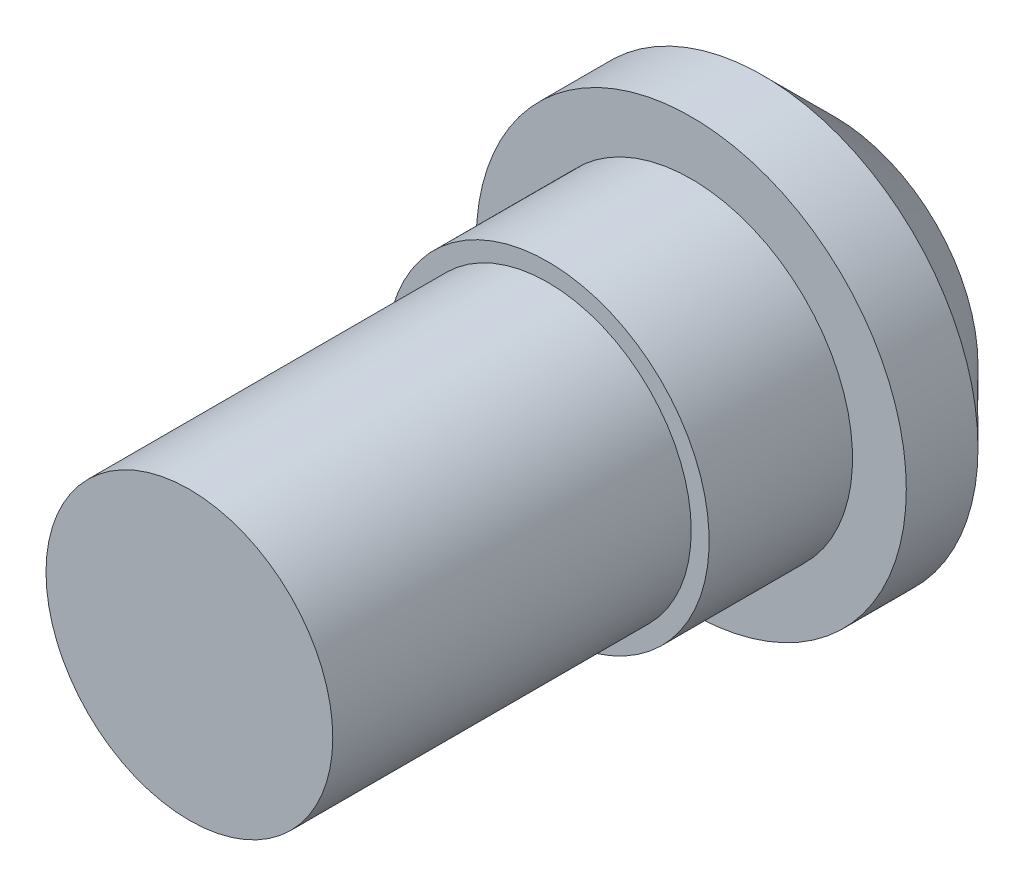
from build123d import *


with BuildPart() as part:
    # Эскиз1 → Повернуть1 (revolve)
    with BuildSketch(Plane(origin=(0, 0, 0), x_dir=(0, 0, -1), z_dir=(1, 0, 0))):
        Polygon((0, 0), (0, 4.000000002), (-2, 6.000000002), (-4, 6.000000002), (-4, 4.5), (-8, 4.5), (-8, 4.000000002), (-18, 4.000000002), (-18, 0), align=None)
    revolve(axis=Axis((0, 0, 0), (0, 0, 1)))


solid = part.part
